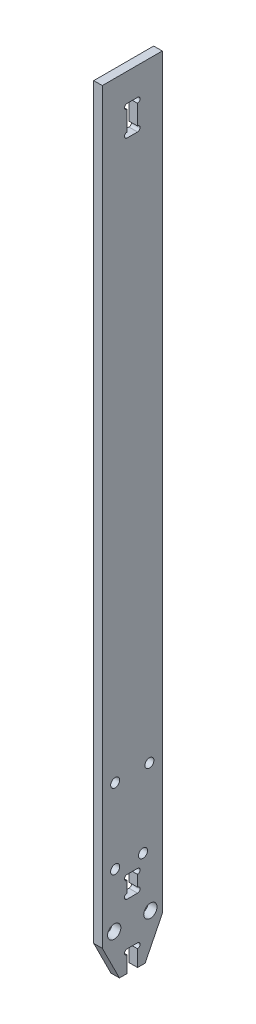
from build123d import *

# Parameters (mm, degrees)
SKETCH_1_W           = 14
SKETCH_1_H           = 182.5
EXTRUDE_1_DEPTH      = 1
SKETCH_2_W           = 2.45
SKETCH_2_H           = 5
CUT_EXTRUDE_1_DEPTH  = 3
SKETCH_3_R           = 0.6
CUT_EXTRUDE_2_DEPTH  = 3
SKETCH_6_W           = 2.45
SKETCH_6_H           = 5
CUT_EXTRUDE_4_DEPTH  = 3
SKETCH_7_R           = 0.6
CUT_EXTRUDE_5_DEPTH  = 3
SKETCH_8_R           = 1.55
CUT_EXTRUDE_6_DEPTH  = 3
SKETCH_9_W           = 2.45
SKETCH_9_H           = 7
CUT_EXTRUDE_7_DEPTH  = 3
SKETCH_10_R          = 0.6
CUT_EXTRUDE_8_DEPTH  = 3
CUT_EXTRUDE_9_DEPTH  = 3
SKETCH_12_R          = 1.05
CUT_EXTRUDE_10_DEPTH = 3
SKETCH_14_R          = 1.05
CUT_EXTRUDE_11_DEPTH = 3
SKETCH_15_R          = 1.05
CUT_EXTRUDE_12_DEPTH = 3


with BuildPart() as part:
    # 草图1 → 凸台-拉伸1 (new body, symmetric)
    with BuildSketch(Plane(origin=(0, 0, 0), x_dir=(0, 0, -1), z_dir=(1, 0, 0))):
        Rectangle(SKETCH_1_W, SKETCH_1_H)
    extrude(amount=EXTRUDE_1_DEPTH, both=True)

    # 草图2 → 切除-拉伸1 (cut, through all)
    with BuildSketch(Plane(origin=(1, 0, 0), x_dir=(0, 0, -1), z_dir=(1, 0, 0))):
        with Locations((0, -88.75)):
            Rectangle(SKETCH_2_W, SKETCH_2_H)
    extrude(amount=-CUT_EXTRUDE_1_DEPTH, mode=Mode.SUBTRACT)

    # 草图3 → 切除-拉伸2 (cut, through all)
    with BuildSketch(Plane(origin=(1, 0, 0), x_dir=(0, 0, -1), z_dir=(1, 0, 0))):
        with Locations((-1.225, -86.85)):
            Circle(SKETCH_3_R)
        with Locations((1.225, -86.85)):
            Circle(SKETCH_3_R)
    extrude(amount=-CUT_EXTRUDE_2_DEPTH, mode=Mode.SUBTRACT)

    # 草图6 → 切除-拉伸4 (cut, through all)
    with BuildSketch(Plane(origin=(1, 0, 0), x_dir=(0, 0, -1), z_dir=(1, 0, 0))):
        with Locations((0, -73.7)):
            Rectangle(SKETCH_6_W, SKETCH_6_H)
    extrude(amount=-CUT_EXTRUDE_4_DEPTH, mode=Mode.SUBTRACT)

    # 草图7 → 切除-拉伸5 (cut, through all)
    with BuildSketch(Plane(origin=(1, 0, 0), x_dir=(0, 0, -1), z_dir=(1, 0, 0))):
        with Locations((-1.225, -71.8)):
            Circle(SKETCH_7_R)
        with Locations((-1.225, -75.6)):
            Circle(SKETCH_7_R)
        with Locations((1.225, -71.8)):
            Circle(SKETCH_7_R)
        with Locations((1.225, -75.6)):
            Circle(SKETCH_7_R)
    extrude(amount=-CUT_EXTRUDE_5_DEPTH, mode=Mode.SUBTRACT)

    # 草图8 → 切除-拉伸6 (cut, through all)
    with BuildSketch(Plane(origin=(1, 0, 0), x_dir=(0, 0, -1), z_dir=(1, 0, 0))):
        with Locations((-4.225, -81.25)):
            Circle(SKETCH_8_R)
        with Locations((4.225, -81.25)):
            Circle(SKETCH_8_R)
    extrude(amount=-CUT_EXTRUDE_6_DEPTH, mode=Mode.SUBTRACT)

    # 草图9 → 切除-拉伸7 (cut, through all)
    with BuildSketch(Plane(origin=(1, 0, 0), x_dir=(0, 0, -1), z_dir=(1, 0, 0))):
        with Locations((0, 81.25)):
            Rectangle(SKETCH_9_W, SKETCH_9_H)
    extrude(amount=-CUT_EXTRUDE_7_DEPTH, mode=Mode.SUBTRACT)

    # 草图10 → 切除-拉伸8 (cut, through all)
    with BuildSketch(Plane(origin=(1, 0, 0), x_dir=(0, 0, -1), z_dir=(1, 0, 0))):
        with Locations((-1.225, 84.15)):
            Circle(SKETCH_10_R)
        with Locations((-1.225, 78.35)):
            Circle(SKETCH_10_R)
        with Locations((1.225, 84.15)):
            Circle(SKETCH_10_R)
        with Locations((1.225, 78.35)):
            Circle(SKETCH_10_R)
    extrude(amount=-CUT_EXTRUDE_8_DEPTH, mode=Mode.SUBTRACT)

    # 草图11 → 切除-拉伸9 (cut, through all)
    with BuildSketch(Plane(origin=(1, 0, 0), x_dir=(0, 0, -1), z_dir=(1, 0, 0))):
        Polygon((-3, -91.25), (-7, -83.25), (-7, -91.25), align=None)
        Polygon((7, -83.25), (7, -91.25), (3, -91.25), align=None)
    extrude(amount=-CUT_EXTRUDE_9_DEPTH, mode=Mode.SUBTRACT)

    # 草图12 → 切除-拉伸10 (cut, through all)
    with BuildSketch(Plane(origin=(1, 0, 0), x_dir=(0, 0, -1), z_dir=(1, 0, 0))):
        with Locations((-4, -68.75)):
            Circle(SKETCH_12_R)
    extrude(amount=-CUT_EXTRUDE_10_DEPTH, mode=Mode.SUBTRACT)

    # 草图14 → 切除-拉伸11 (cut, through all)
    with BuildSketch(Plane.ZY.offset(1)):
        with Locations((-2.5, -68.75)):
            Circle(SKETCH_14_R)
    extrude(amount=-CUT_EXTRUDE_11_DEPTH, mode=Mode.SUBTRACT)

    # 草图15 → 切除-拉伸12 (cut, through all)
    with BuildSketch(Plane.ZY.offset(1)):
        with Locations((-4, -51.25)):
            Circle(SKETCH_15_R)
        with Locations((4, -51.25)):
            Circle(SKETCH_15_R)
    extrude(amount=-CUT_EXTRUDE_12_DEPTH, mode=Mode.SUBTRACT)


solid = part.part
